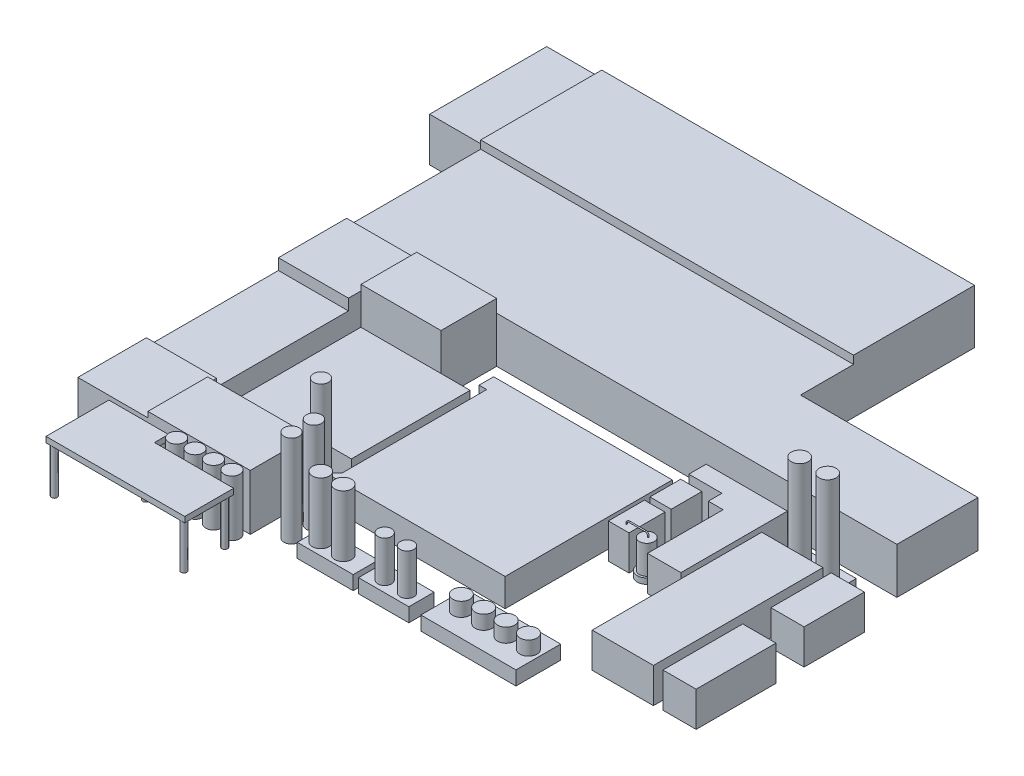
from build123d import *

# Parameters (mm, degrees)
SKETCH1_W              = 10.36
SKETCH1_H              = 20.93
BOSS_EXTRUDE1_DEPTH    = 7.85
SKETCH2_W              = 66.62
SKETCH2_H              = 21.63
BOSS_EXTRUDE2_DEPTH    = 9.66
BOSS_EXTRUDE3_DEPTH    = 8.22
SKETCH4_W              = 12.52
SKETCH4_H              = 12.2
BOSS_EXTRUDE4_DEPTH    = 9.51
SKETCH5_W              = 14.29
SKETCH5_H              = 9.95
BOSS_EXTRUDE5_DEPTH    = 10.52
SKETCH6_W              = 12.52
SKETCH6_H              = 23.58
BOSS_EXTRUDE6_DEPTH    = 7.53
SKETCH7_W              = 12.52
SKETCH7_H              = 12.26
BOSS_EXTRUDE7_DEPTH    = 8.91
SKETCH8_W              = 18.29
SKETCH8_H              = 10.68
BOSS_EXTRUDE8_DEPTH    = 9.91
SKETCH10_R             = 1.345
BOSS_EXTRUDE10_DEPTH   = 16.39
BOSS_EXTRUDE10_2_DEPTH = 16.39
SKETCH11_W             = 10
SKETCH11_H             = 4.5
BOSS_EXTRUDE11_DEPTH   = 2.5
SKETCH11_W_2           = 9
BOSS_EXTRUDE11_2_DEPTH = 2.5
SKETCH12_R             = 1.5
BOSS_EXTRUDE12_DEPTH   = 10.94
SKETCH13_R             = 1.22
BOSS_EXTRUDE13_DEPTH   = 7.34
SKETCH14_W             = 10
SKETCH14_H             = 5
BOSS_EXTRUDE14_DEPTH   = 1.5
SKETCH15_R             = 1.5
BOSS_EXTRUDE15_DEPTH   = 16.38
SKETCH16_W             = 10.94
SKETCH16_H             = 30.29
BOSS_EXTRUDE16_DEPTH   = 6.23
SKETCH16_W_2           = 5.94
SKETCH16_H_2           = 10.78
BOSS_EXTRUDE16_2_DEPTH = 6.23
SKETCH16_H_3           = 14.260881044
BOSS_EXTRUDE16_3_DEPTH = 6.23
SKETCH18_W             = 17
SKETCH18_H             = 8
BOSS_EXTRUDE17_DEPTH   = 2.5
SKETCH19_R             = 1.52
BOSS_EXTRUDE18_DEPTH   = 2.5
BOSS_EXTRUDE19_DEPTH   = 5
BOSS_EXTRUDE19_2_DEPTH = 5
SKETCH21_W             = 3
SKETCH21_H             = 3
BOSS_EXTRUDE20_DEPTH   = 1
SKETCH22_R             = 1.345
BOSS_EXTRUDE21_DEPTH   = 16.38
BOSS_EXTRUDE22_DEPTH   = 6.23
SKETCH24_W             = 3.684487604
SKETCH24_H             = 6.433232324
BOSS_EXTRUDE23_DEPTH   = 6.23
SKETCH24_W_2           = 3.8
SKETCH24_H_2           = 5.5
BOSS_EXTRUDE23_2_DEPTH = 6.23
SKETCH25_R             = 1.671937508
BOSS_EXTRUDE24_DEPTH   = 1
SKETCH26_R             = 1.32
BOSS_EXTRUDE25_DEPTH   = 5.11
SKETCH27_R             = 0.1
SKETCH30_R             = 0.517908229
BOSS_EXTRUDE26_DEPTH   = 8
BOSS_EXTRUDE26_2_DEPTH = 8
BOSS_EXTRUDE26_3_DEPTH = 8
BOSS_EXTRUDE26_4_DEPTH = 8
BOSS_EXTRUDE26_5_DEPTH = 8
BOSS_EXTRUDE26_6_DEPTH = 8
BOSS_EXTRUDE28_DEPTH   = 1
SKETCH33_R             = 1.4
BOSS_EXTRUDE29_DEPTH   = 10
BOSS_EXTRUDE29_2_DEPTH = 10
BOSS_EXTRUDE29_3_DEPTH = 10
BOSS_EXTRUDE29_4_DEPTH = 10


with BuildPart() as part:
    # Sketch1 → Boss-Extrude1 (new body)
    with BuildSketch(Plane(origin=(0, 0, 0), x_dir=(1, 0, 0), z_dir=(0, 1, 0))):
        with Locations((-5.18, -10.465)):
            Rectangle(SKETCH1_W, SKETCH1_H)
    extrude(amount=BOSS_EXTRUDE1_DEPTH)

    # Sketch2 → Boss-Extrude2 (add)
    with BuildSketch(Plane(origin=(0, 0, 0), x_dir=(1, 0, 0), z_dir=(0, 1, 0))):
        with Locations((33.31, -11.336572093)):
            Rectangle(SKETCH2_W, SKETCH2_H)
    extrude(amount=BOSS_EXTRUDE2_DEPTH)

    # Sketch3 → Boss-Extrude3 (add)
    with BuildSketch(Plane(origin=(0, 0, 0), x_dir=(1, 0, 0), z_dir=(0, 1, 0))):
        Polygon((0, -22.151572093), (0, -46.111572093), (98.34, -46.111572093), (98.34, -31.621572093), (68.864066924, -31.621572093), (66.62, -31.621572093), (66.62, -22.151572093), align=None)
    extrude(amount=BOSS_EXTRUDE3_DEPTH)

    # Sketch4 → Boss-Extrude4 (add)
    with BuildSketch(Plane(origin=(0, 0, 0), x_dir=(1, 0, 0), z_dir=(0, 1, 0))):
        with Locations((6.26, -52.211572093)):
            Rectangle(SKETCH4_W, SKETCH4_H)
    extrude(amount=BOSS_EXTRUDE4_DEPTH)

    # Sketch5 → Boss-Extrude5 (add)
    with BuildSketch(Plane(origin=(0, 0, 0), x_dir=(1, 0, 0), z_dir=(0, 1, 0))):
        with Locations((19.665, -51.086572093)):
            Rectangle(SKETCH5_W, SKETCH5_H)
    extrude(amount=BOSS_EXTRUDE5_DEPTH)

    # Sketch6 → Boss-Extrude6 (add)
    with BuildSketch(Plane(origin=(0, 0, 0), x_dir=(1, 0, 0), z_dir=(0, 1, 0))):
        with Locations((6.26, -70.101572093)):
            Rectangle(SKETCH6_W, SKETCH6_H)
    extrude(amount=BOSS_EXTRUDE6_DEPTH)

    # Sketch7 → Boss-Extrude7 (add)
    with BuildSketch(Plane(origin=(0, 0, 0), x_dir=(1, 0, 0), z_dir=(0, 1, 0))):
        with Locations((6.26, -88.021572093)):
            Rectangle(SKETCH7_W, SKETCH7_H)
    extrude(amount=BOSS_EXTRUDE7_DEPTH)

    # Sketch8 → Boss-Extrude8 (add)
    with BuildSketch(Plane(origin=(0, 0, 0), x_dir=(1, 0, 0), z_dir=(0, 1, 0))):
        with Locations((21.665, -88.811572093)):
            Rectangle(SKETCH8_W, SKETCH8_H)
    extrude(amount=BOSS_EXTRUDE8_DEPTH)


with BuildPart() as body_2:
    # Sketch10 → Boss-Extrude10 (new body)
    with BuildSketch(Plane(origin=(0, 0, 0), x_dir=(1, 0, 0), z_dir=(0, 1, 0))):
        with Locations((35.033675918, -87.001193803)):
            Circle(SKETCH10_R)
    extrude(amount=BOSS_EXTRUDE10_DEPTH)


with BuildPart() as body_3:
    # Sketch10 → Boss-Extrude10 2 (new body)
    with BuildSketch(Plane(origin=(0, 0, 0), x_dir=(1, 0, 0), z_dir=(0, 1, 0))):
        with Locations((35.033675918, -91.001193803)):
            Circle(SKETCH10_R)
    extrude(amount=BOSS_EXTRUDE10_2_DEPTH)


with BuildPart() as body_4:
    # Sketch11 → Boss-Extrude11 (new body)
    with BuildSketch(Plane(origin=(0, 0, 0), x_dir=(1, 0, 0), z_dir=(0, 1, 0))):
        with Locations((43.720174726, -91.411209201)):
            Rectangle(SKETCH11_W, SKETCH11_H)
    extrude(amount=BOSS_EXTRUDE11_DEPTH)

    # Sketch12 → Boss-Extrude12 (add)
    with BuildSketch(Plane(origin=(0, 2.5, 0), x_dir=(1, 0, 0), z_dir=(0, 1, 0))):
        with Locations((40.764598791, -91.490566851)):
            Circle(SKETCH12_R)
        with Locations((44.764598791, -91.490566851)):
            Circle(SKETCH12_R)
    extrude(amount=BOSS_EXTRUDE12_DEPTH)


with BuildPart() as body_5:
    # Sketch11 → Boss-Extrude11 2 (new body)
    with BuildSketch(Plane(origin=(0, 0, 0), x_dir=(1, 0, 0), z_dir=(0, 1, 0))):
        with Locations((54.164950947, -91.411209201)):
            Rectangle(SKETCH11_W_2, SKETCH11_H)
    extrude(amount=BOSS_EXTRUDE11_2_DEPTH)

    # Sketch13 → Boss-Extrude13 (add)
    with BuildSketch(Plane(origin=(0, 2.5, 0), x_dir=(1, 0, 0), z_dir=(0, 1, 0))):
        with Locations((52.36684013, -91.68342579)):
            Circle(SKETCH13_R)
        with Locations((56.36684013, -91.68342579)):
            Circle(SKETCH13_R)
    extrude(amount=BOSS_EXTRUDE13_DEPTH)


with BuildPart() as body_6:
    # Sketch14 → Boss-Extrude14 (new body)
    with BuildSketch(Plane(origin=(0, 0, 0), x_dir=(1, 0, 0), z_dir=(0, 1, 0))):
        with Locations((88.279748806, -50.821440592)):
            Rectangle(SKETCH14_W, SKETCH14_H)
    extrude(amount=BOSS_EXTRUDE14_DEPTH)

    # Sketch15 → Boss-Extrude15 (add)
    with BuildSketch(Plane(origin=(0, 1.5, 0), x_dir=(1, 0, 0), z_dir=(0, 1, 0))):
        with Locations((85.779748806, -50.931575511)):
            Circle(SKETCH15_R)
        with Locations((90.779748806, -50.931575511)):
            Circle(SKETCH15_R)
    extrude(amount=BOSS_EXTRUDE15_DEPTH)


with BuildPart() as body_7:
    # Sketch16 → Boss-Extrude16 (new body)
    with BuildSketch(Plane(origin=(0, 0, 0), x_dir=(1, 0, 0), z_dir=(0, 1, 0))):
        with Locations((87.868386961, -69.475902829)):
            Rectangle(SKETCH16_W, SKETCH16_H)
    extrude(amount=BOSS_EXTRUDE16_DEPTH)


with BuildPart() as body_8:
    # Sketch16 → Boss-Extrude16 2 (new body)
    with BuildSketch(Plane(origin=(0, 0, 0), x_dir=(1, 0, 0), z_dir=(0, 1, 0))):
        with Locations((97.858563425, -59.798704664)):
            Rectangle(SKETCH16_W_2, SKETCH16_H_2)
    extrude(amount=BOSS_EXTRUDE16_2_DEPTH)


with BuildPart() as body_9:
    # Sketch16 → Boss-Extrude16 3 (new body)
    with BuildSketch(Plane(origin=(0, 0, 0), x_dir=(1, 0, 0), z_dir=(0, 1, 0))):
        with Locations((97.858563425, -77.35066232)):
            Rectangle(SKETCH16_W_2, SKETCH16_H_3)
    extrude(amount=BOSS_EXTRUDE16_3_DEPTH)


with BuildPart() as body_10:
    # Sketch18 → Boss-Extrude17 (new body)
    with BuildSketch(Plane(origin=(0, 0, 0), x_dir=(1, 0, 0), z_dir=(0, 1, 0))):
        with Locations((69.511593708, -89.867772455)):
            Rectangle(SKETCH18_W, SKETCH18_H)
    extrude(amount=BOSS_EXTRUDE17_DEPTH)

    # Sketch19 → Boss-Extrude18 (add)
    with BuildSketch(Plane(origin=(0, 2.5, 0), x_dir=(1, 0, 0), z_dir=(0, 1, 0))):
        with Locations((63.939014582, -89.557192754)):
            Circle(SKETCH19_R)
        with Locations((67.939014582, -89.557192754)):
            Circle(SKETCH19_R)
        with Locations((71.939014582, -89.557192754)):
            Circle(SKETCH19_R)
        with Locations((75.939014582, -89.557192754)):
            Circle(SKETCH19_R)
    extrude(amount=BOSS_EXTRUDE18_DEPTH)


with BuildPart() as body_11:
    # Sketch20 → Boss-Extrude19 (new body)
    with BuildSketch(Plane(origin=(0, 0, 0), x_dir=(1, 0, 0), z_dir=(0, 1, 0))):
        Polygon((13.621148962, -57.196823653), (13.621148962, -82.070958585), (27.713662268, -82.070958585), (27.713662268, -78.42048827), (33.14692041, -78.42048827), (33.14692041, -57.196823653), align=None)
    extrude(amount=BOSS_EXTRUDE19_DEPTH)


with BuildPart() as body_12:
    # Sketch20 → Boss-Extrude19 2 (new body)
    with BuildSketch(Plane(origin=(0, 0, 0), x_dir=(1, 0, 0), z_dir=(0, 1, 0))):
        Polygon((33.14692041, -82.873811145), (65.081796973, -82.873811145), (65.081796973, -52.992179694), (33.14692041, -52.992179694), (33.14692041, -55.593878248), (34.510118793, -55.593878248), (34.510118793, -81.453640165), align=None)
    extrude(amount=BOSS_EXTRUDE19_2_DEPTH)


with BuildPart() as body_13:
    # Sketch21 → Boss-Extrude20 (new body)
    with BuildSketch(Plane(origin=(0, 0, 0), x_dir=(1, 0, 0), z_dir=(0, 1, 0))):
        with Locations((30.291799227, -80.946411686)):
            Rectangle(SKETCH21_W, SKETCH21_H)
    extrude(amount=BOSS_EXTRUDE20_DEPTH)

    # Sketch22 → Boss-Extrude21 (add)
    with BuildSketch(Plane(origin=(0, 1, 0), x_dir=(1, 0, 0), z_dir=(0, 1, 0))):
        with Locations((30.291799227, -80.989393406)):
            Circle(SKETCH22_R)
    extrude(amount=BOSS_EXTRUDE21_DEPTH)


with BuildPart() as body_14:
    # Sketch23 → Boss-Extrude22 (new body)
    with BuildSketch(Plane(origin=(0, 0, 0), x_dir=(1, 0, 0), z_dir=(0, 1, 0))):
        Polygon((73.822706474, -48.763267888), (81.425617402, -48.763267888), (81.425617402, -67.800474753), (75.460398946, -67.800474753), (75.460398946, -54.294118428), (72.814823996, -54.294118428), (72.814823996, -51.857404659), (66.897090554, -51.857404659), (66.897090554, -48.763267888), align=None)
    extrude(amount=BOSS_EXTRUDE22_DEPTH)


with BuildPart() as body_15:
    # Sketch24 → Boss-Extrude23 (new body)
    with BuildSketch(Plane(origin=(0, 0, 0), x_dir=(1, 0, 0), z_dir=(0, 1, 0))):
        with Locations((68.791072004, -63.069334456)):
            Rectangle(SKETCH24_W, SKETCH24_H)
    extrude(amount=BOSS_EXTRUDE23_DEPTH)



with BuildPart() as body_16:
    # Sketch24 → Boss-Extrude23 2 (new body)
    with BuildSketch(Plane(origin=(0, 0, 0), x_dir=(1, 0, 0), z_dir=(0, 1, 0))):
        with Locations((68.848828202, -56.111002039)):
            Rectangle(SKETCH24_W_2, SKETCH24_H_2)
    extrude(amount=BOSS_EXTRUDE23_2_DEPTH)


with BuildPart() as body_17:
    # Sketch25 → Boss-Extrude24 (new body)
    with BuildSketch(Plane(origin=(0, 0, 0), x_dir=(1, 0, 0), z_dir=(0, 1, 0))):
        with Locations((72.767546987, -65.280679878)):
            Circle(SKETCH25_R)
    extrude(amount=BOSS_EXTRUDE24_DEPTH)

    # Sketch26 → Boss-Extrude25 (add)
    with BuildSketch(Plane(origin=(0, 1, 0), x_dir=(1, 0, 0), z_dir=(0, 1, 0))):
        with Locations((72.789071892, -65.267875341)):
            Circle(SKETCH26_R)
    extrude(amount=BOSS_EXTRUDE25_DEPTH)


with BuildPart() as body_15_1:
    add(body_15.part)

    add(body_17.part)  # Sweep1 merges body 17
    # Sweep1: sweep along a curve in space
    with BuildLine() as sweep1_path:
        Line((72.926154688, 6.11, 65.111874753), (72.926154688, 6.302788861, 65.111874753))
        ThreePointArc((72.426154688, 6.802788861, 65.111874753), (72.779708079, 6.656342252, 65.111874753), (72.926154688, 6.302788861, 65.111874753))
        Line((72.426154688, 6.802788861, 65.111874753), (69.53389529, 6.802788861, 65.111874753))
        ThreePointArc((69.53389529, 6.802788861, 65.111874753), (69.1803419, 6.656342252, 65.111874753), (69.03389529, 6.302788861, 65.111874753))
        Line((69.03389529, 6.302788861, 65.111874753), (69.03389529, 6.024459855, 65.111874753))
    # Sketch27 → Sweep1 (sweep)
    with BuildSketch(Plane(origin=(0, 6.11, 0), x_dir=(1, 0, 0), z_dir=(0, 1, 0))):
        with Locations((72.926154688, -65.111874753)):
            Circle(SKETCH27_R)
    sweep(path=sweep1_path.line)


with BuildPart() as body_17_2:
    # Sketch30 → Boss-Extrude26 (new body)
    with BuildSketch(Plane(origin=(0, 0, 0), x_dir=(1, 0, 0), z_dir=(0, 1, 0))):
        with Locations((7.335209946, -94.979490453)):
            Circle(SKETCH30_R)
    extrude(amount=BOSS_EXTRUDE26_DEPTH)



with BuildPart() as body_18:
    # Sketch30 → Boss-Extrude26 2 (new body)
    with BuildSketch(Plane(origin=(0, 0, 0), x_dir=(1, 0, 0), z_dir=(0, 1, 0))):
        with Locations((7.335209946, -105.689490453)):
            Circle(SKETCH30_R)
    extrude(amount=BOSS_EXTRUDE26_2_DEPTH)


with BuildPart() as body_19:
    # Sketch30 → Boss-Extrude26 3 (new body)
    with BuildSketch(Plane(origin=(0, 0, 0), x_dir=(1, 0, 0), z_dir=(0, 1, 0))):
        with Locations((16.105209946, -98.139490453)):
            Circle(SKETCH30_R)
    extrude(amount=BOSS_EXTRUDE26_3_DEPTH)


with BuildPart() as body_20:
    # Sketch30 → Boss-Extrude26 4 (new body)
    with BuildSketch(Plane(origin=(0, 0, 0), x_dir=(1, 0, 0), z_dir=(0, 1, 0))):
        with Locations((30.485209946, -98.387000575)):
            Circle(SKETCH30_R)
    extrude(amount=BOSS_EXTRUDE26_4_DEPTH)


with BuildPart() as body_21:
    # Sketch30 → Boss-Extrude26 5 (new body)
    with BuildSketch(Plane(origin=(0, 0, 0), x_dir=(1, 0, 0), z_dir=(0, 1, 0))):
        with Locations((30.489431813, -105.689490453)):
            Circle(SKETCH30_R)
    extrude(amount=BOSS_EXTRUDE26_5_DEPTH)


with BuildPart() as body_22:
    # Sketch30 → Boss-Extrude26 6 (new body)
    with BuildSketch(Plane(origin=(0, 0, 0), x_dir=(1, 0, 0), z_dir=(0, 1, 0))):
        with Locations((16.105209946, -94.979490453)):
            Circle(SKETCH30_R)
    extrude(amount=BOSS_EXTRUDE26_6_DEPTH)


with BuildPart() as body_17_2_1:
    add(body_17_2.part)

    add(body_18.part)  # Boss-Extrude28 merges body 18

    add(body_19.part)  # Boss-Extrude28 merges body 19

    add(body_20.part)  # Boss-Extrude28 merges body 20

    add(body_21.part)  # Boss-Extrude28 merges body 21

    add(body_22.part)  # Boss-Extrude28 merges body 22
    # Sketch32 → Boss-Extrude28 (add)
    with BuildSketch(Plane(origin=(0, 8, 0), x_dir=(1, 0, 0), z_dir=(0, 1, 0))):
        Polygon((7.335209946, -94.979490453), (16.105209946, -94.979490453), (17.021880741, -94.979490453), (17.021880741, -97.481510797), (31.173774201, -97.481510797), (31.173774201, -106.216860964), (6.376651146, -106.216860964), (6.376651146, -105.689490453), (6.376651146, -94.979490453), align=None)
    extrude(amount=BOSS_EXTRUDE28_DEPTH)


with BuildPart() as body_18_2:
    # Sketch33 → Boss-Extrude29 (new body)
    with BuildSketch(Plane(origin=(0, 0, 0), x_dir=(1, 0, 0), z_dir=(0, 1, 0))):
        with Locations((19.253120808, -95.760080036)):
            Circle(SKETCH33_R)
    extrude(amount=BOSS_EXTRUDE29_DEPTH)


with BuildPart() as body_19_2:
    # Sketch33 → Boss-Extrude29 2 (new body)
    with BuildSketch(Plane(origin=(0, 0, 0), x_dir=(1, 0, 0), z_dir=(0, 1, 0))):
        with Locations((22.553120808, -95.760080036)):
            Circle(SKETCH33_R)
    extrude(amount=BOSS_EXTRUDE29_2_DEPTH)


with BuildPart() as body_20_2:
    # Sketch33 → Boss-Extrude29 3 (new body)
    with BuildSketch(Plane(origin=(0, 0, 0), x_dir=(1, 0, 0), z_dir=(0, 1, 0))):
        with Locations((25.853120808, -95.760080036)):
            Circle(SKETCH33_R)
    extrude(amount=BOSS_EXTRUDE29_3_DEPTH)


with BuildPart() as body_21_2:
    # Sketch33 → Boss-Extrude29 4 (new body)
    with BuildSketch(Plane(origin=(0, 0, 0), x_dir=(1, 0, 0), z_dir=(0, 1, 0))):
        with Locations((29.153120808, -95.760080036)):
            Circle(SKETCH33_R)
    extrude(amount=BOSS_EXTRUDE29_4_DEPTH)


solid = Compound([part.part, body_2.part, body_3.part, body_4.part, body_5.part, body_6.part, body_7.part, body_8.part, body_9.part, body_10.part, body_11.part, body_12.part, body_13.part, body_14.part, body_16.part, body_15_1.part, body_17_2_1.part, body_18_2.part, body_19_2.part, body_20_2.part, body_21_2.part])
